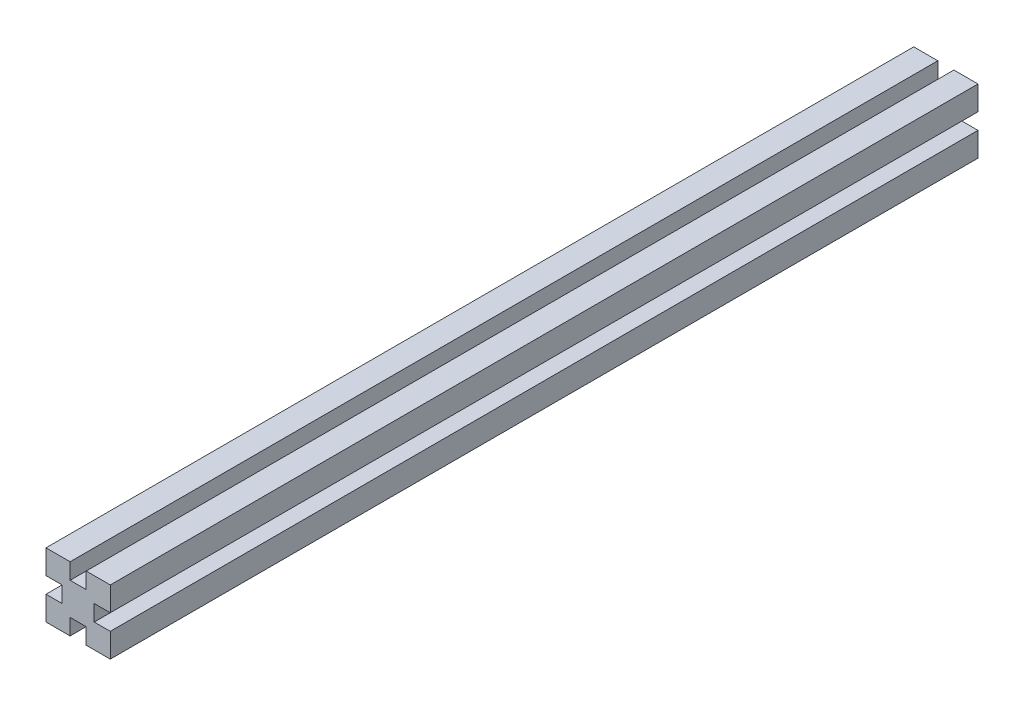
from build123d import *

# Parameters (mm, degrees)
SKETCH1_W           = 20
SKETCH1_H           = 20
BOSS_EXTRUDE1_DEPTH = 270
SKETCH1_3_W         = 5
SKETCH1_3_H         = 10
CUT_EXTRUDE1_DEPTH  = 645
CIRPATTERN1_COUNT   = 4


with BuildPart() as part:
    # Sketch1 → Boss-Extrude1 (new body)
    with BuildSketch(Plane.XY):
        Rectangle(SKETCH1_W, SKETCH1_H)
    extrude(amount=-BOSS_EXTRUDE1_DEPTH)

    # Sketch1_3 → Cut-Extrude1 (cut)
    with BuildSketch(Plane.XY):
        with Locations((0, 10)):
            Rectangle(SKETCH1_3_W, SKETCH1_3_H)
    cut_extrude1 = extrude(amount=-CUT_EXTRUDE1_DEPTH, mode=Mode.SUBTRACT)

    # CirPattern1: Cut-Extrude1 ×4 about axis
    cirpattern1_axis = Axis((0, 0, 32.25), (0, 0, -1))
    for i in range(1, CIRPATTERN1_COUNT):
        add(cut_extrude1.rotate(cirpattern1_axis, i * 360 / CIRPATTERN1_COUNT), mode=Mode.SUBTRACT)


solid = part.part
